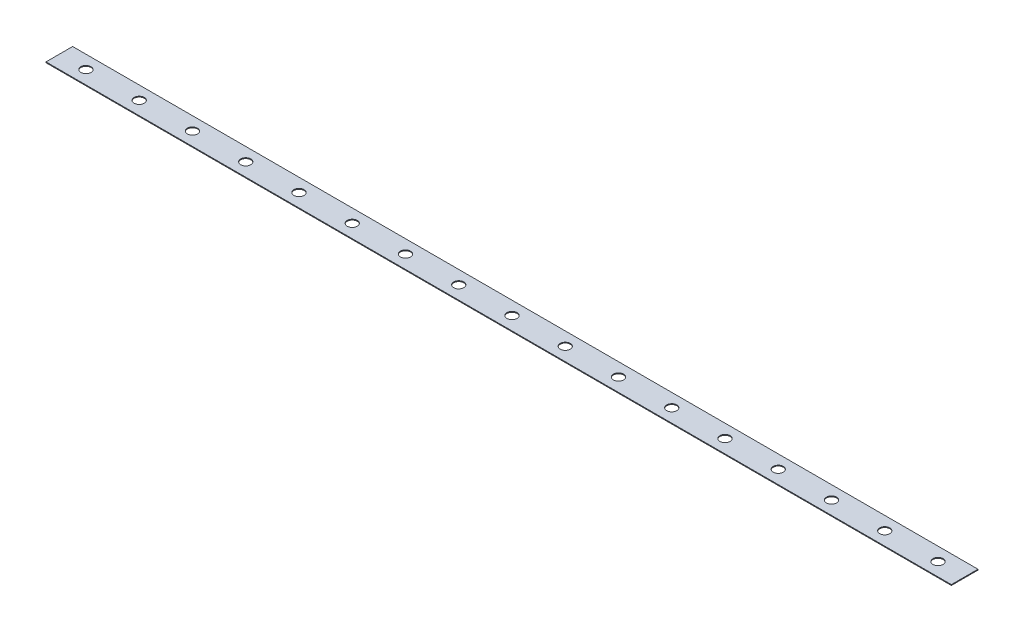
from build123d import *

# Parameters (mm, degrees)
SKETCH1_W           = 431.8
SKETCH1_H           = 12.7
BOSS_EXTRUDE1_DEPTH = 0.381
SKETCH2_R           = 2.413
CUT_EXTRUDE1_DEPTH  = 1.381


with BuildPart() as part:
    # Sketch1 → Boss-Extrude1 (new body)
    with BuildSketch(Plane(origin=(0, 0, 0), x_dir=(1, 0, 0), z_dir=(0, 1, 0))):
        Rectangle(SKETCH1_W, SKETCH1_H)
    extrude(amount=BOSS_EXTRUDE1_DEPTH)

    # Sketch2 → Cut-Extrude1 (cut, through all)
    with BuildSketch(Plane(origin=(0, 0.381, 0), x_dir=(1, 0, 0), z_dir=(0, 1, 0))):
        Circle(SKETCH2_R)
        with Locations((-25.4, 0)):
            Circle(SKETCH2_R)
        with Locations((25.4, 0)):
            Circle(SKETCH2_R)
        with Locations((-50.8, 0)):
            Circle(SKETCH2_R)
        with Locations((-76.2, 0)):
            Circle(SKETCH2_R)
        with Locations((-101.6, 0)):
            Circle(SKETCH2_R)
        with Locations((-127, 0)):
            Circle(SKETCH2_R)
        with Locations((-152.4, 0)):
            Circle(SKETCH2_R)
        with Locations((-177.8, 0)):
            Circle(SKETCH2_R)
        with Locations((-203.2, 0)):
            Circle(SKETCH2_R)
        with Locations((50.8, 0)):
            Circle(SKETCH2_R)
        with Locations((76.2, 0)):
            Circle(SKETCH2_R)
        with Locations((101.6, 0)):
            Circle(SKETCH2_R)
        with Locations((127, 0)):
            Circle(SKETCH2_R)
        with Locations((152.4, 0)):
            Circle(SKETCH2_R)
        with Locations((177.8, 0)):
            Circle(SKETCH2_R)
        with Locations((203.2, 0)):
            Circle(SKETCH2_R)
    extrude(amount=-CUT_EXTRUDE1_DEPTH, mode=Mode.SUBTRACT)


solid = part.part
